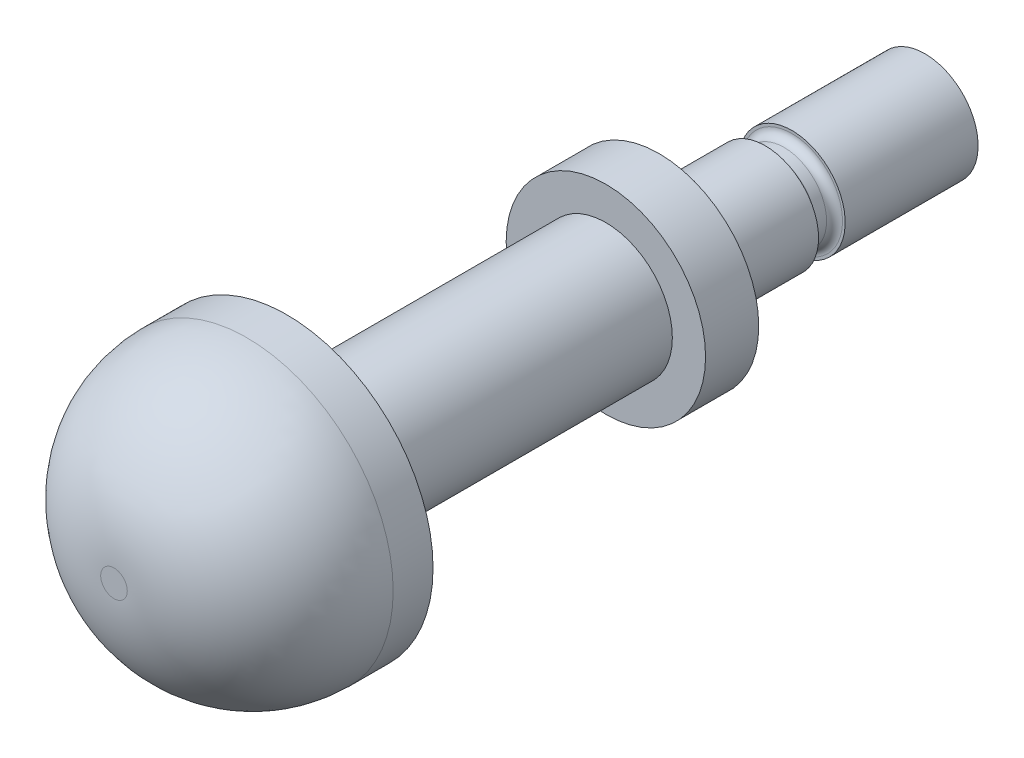
from build123d import *

# Parameters (mm, degrees)
SKETCH1_R           = 2
BOSS_EXTRUDE1_DEPTH = 4
SKETCH2_R           = 3.75
BOSS_EXTRUDE2_DEPTH = 2
SKETCH3_R           = 2.5
BOSS_EXTRUDE3_DEPTH = 12
SKETCH4_R           = 5.5
BOSS_EXTRUDE4_DEPTH = 6.5
FILLET1_R           = 5
SKETCH5_R           = 1.6
BOSS_EXTRUDE5_DEPTH = 1
SKETCH6_R           = 2
BOSS_EXTRUDE6_DEPTH = 5
FILLET2_R           = 0.3


with BuildPart() as part:
    # Sketch1 → Boss-Extrude1 (new body)
    with BuildSketch(Plane.XY):
        Circle(SKETCH1_R)
    extrude(amount=BOSS_EXTRUDE1_DEPTH)

    # Sketch2 → Boss-Extrude2 (add)
    with BuildSketch(Plane.XY.offset(4)):
        Circle(SKETCH2_R)
    extrude(amount=BOSS_EXTRUDE2_DEPTH)

    # Sketch3 → Boss-Extrude3 (add)
    with BuildSketch(Plane.XY.offset(6)):
        Circle(SKETCH3_R)
    extrude(amount=BOSS_EXTRUDE3_DEPTH)

    # Sketch4 → Boss-Extrude4 (add)
    with BuildSketch(Plane.XY.offset(18)):
        Circle(SKETCH4_R)
    extrude(amount=BOSS_EXTRUDE4_DEPTH)

    # Fillet1
    fillet1_edges = [part.edges().sort_by_distance(p)[0] for p in [
        (-5.5, 0, 24.5),
    ]]
    fillet(fillet1_edges, radius=FILLET1_R)

    # Sketch5 → Boss-Extrude5 (add)
    with BuildSketch(Plane(origin=(0, 0, 0), x_dir=(-1, 0, 0), z_dir=(0, 0, -1))):
        Circle(SKETCH5_R)
    extrude(amount=BOSS_EXTRUDE5_DEPTH)

    # Sketch6 → Boss-Extrude6 (add)
    with BuildSketch(Plane(origin=(0, 0, -1), x_dir=(-1, 0, 0), z_dir=(0, 0, -1))):
        Circle(SKETCH6_R)
    extrude(amount=BOSS_EXTRUDE6_DEPTH)

    # Fillet2
    fillet2_edges = [part.edges().sort_by_distance(p)[0] for p in [
        (1.6, 0, 0),
        (1.6, 0, -1),
    ]]
    fillet(fillet2_edges, radius=FILLET2_R)


solid = part.part
